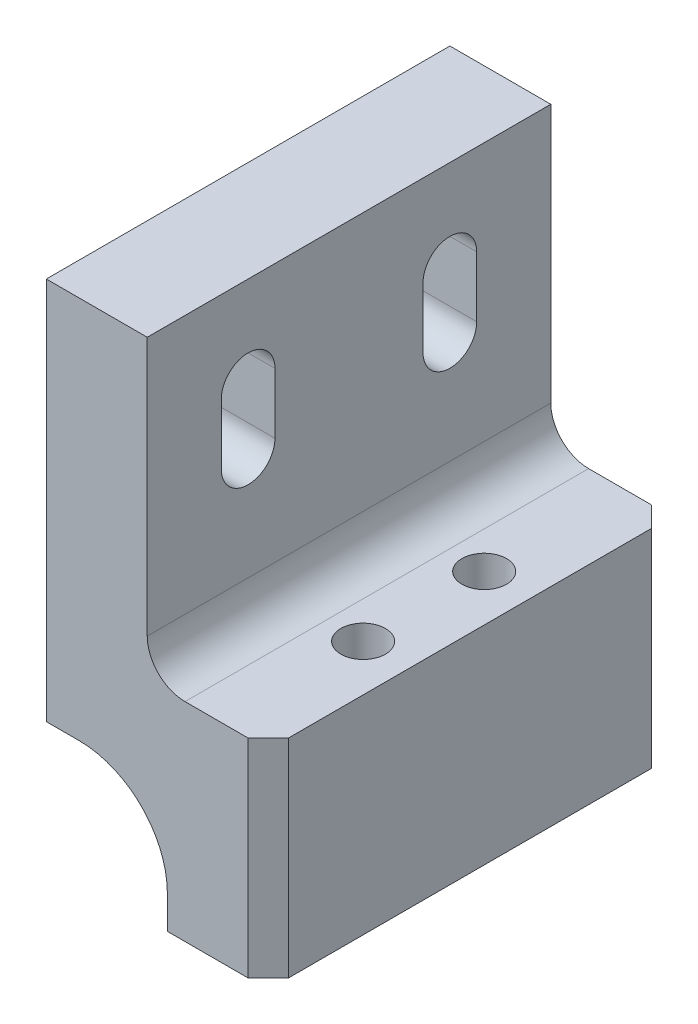
from build123d import *

# Parameters (mm, degrees)
SKETCH1_W              = 55.88
SKETCH1_H              = 63.5
EXTRUDE1_DEPTH         = 25.4
EXTRUDE1_DEPTH_BACK    = 25.4
EXTRUDE2_DEPTH         = 51.8
FILLET1_R              = 11.1125
F_10_CLEARANCE_HOLE1_D = 5.6134
LPATTERN1_COUNT        = 2
LPATTERN1_PITCH        = 15.24
SKETCH9_W              = 15.24
SKETCH9_H              = 37.338
EXTRUDE3_DEPTH         = 51.8
FILLET2_R              = 4.7625
EXTRUDE5_DEPTH         = 13.7
LPATTERN2_COUNT        = 2
LPATTERN2_PITCH        = 25.4
CHAMFER1_SIZE          = 2.54


with BuildPart() as part:
    # Sketch1 → Extrude1 (new body, two sides)
    with BuildSketch(Plane.XY) as extrude1_sk:
        Rectangle(SKETCH1_W, SKETCH1_H)
    extrude(amount=EXTRUDE1_DEPTH)
    extrude(extrude1_sk.sketch, amount=-EXTRUDE1_DEPTH_BACK)

    # Sketch2 → Extrude2 (cut, through all)
    with BuildSketch(Plane.XY.offset(25.4)):
        Polygon((-27.94, -31.75), (15.24, -31.75), (15.24, -16.51), (0, -16.51), (0, 31.75), (-27.94, 31.75), align=None)
    extrude(amount=-EXTRUDE2_DEPTH, mode=Mode.SUBTRACT)

    # Fillet1
    fillet1_edges = [part.edges().sort_by_distance(p)[0] for p in [
        (15.24, -16.51, 0),
    ]]
    fillet(fillet1_edges, radius=FILLET1_R)

    # 10 Clearance Hole1 (through all)
    with Locations(Plane(origin=(0, 31.75, 0), x_dir=(-1, 0, 0), z_dir=(0, 1, 0))):
        with Locations((-22.098, -7.62)):
            f_10_clearance_hole1 = Hole(F_10_CLEARANCE_HOLE1_D / 2)

    # LPattern1: 10 Clearance Hole1 ×2
    with Locations(*[(0, 0, i * LPATTERN1_PITCH) for i in range(1, LPATTERN1_COUNT)]):
        add(f_10_clearance_hole1, mode=Mode.SUBTRACT)

    # Sketch9 → Extrude3 (cut, through all)
    with BuildSketch(Plane.XY.offset(25.4)):
        with Locations((20.32, 13.081)):
            Rectangle(SKETCH9_W, SKETCH9_H)
    extrude(amount=-EXTRUDE3_DEPTH, mode=Mode.SUBTRACT)

    # Fillet2
    fillet2_edges = [part.edges().sort_by_distance(p)[0] for p in [
        (12.7, -5.588, 0),
    ]]
    fillet(fillet2_edges, radius=FILLET2_R)

    # Sketch11 → Extrude5 (cut, through all)
    with BuildSketch(Plane(origin=(12.7, 0, 0), x_dir=(0, 0, -1), z_dir=(1, 0, 0))):
        with BuildLine():
            Line((-9.3218, 20.32), (-9.3218, 12.7))
            ThreePointArc((-9.3218, 12.7), (-12.7, 9.3218), (-16.0782, 12.7))
            Line((-16.0782, 12.7), (-16.0782, 20.32))
            ThreePointArc((-16.0782, 20.32), (-12.7, 23.6982), (-9.3218, 20.32))
        make_face()
    extrude5 = extrude(amount=-EXTRUDE5_DEPTH, mode=Mode.SUBTRACT)

    # LPattern2: Extrude5 ×2
    with Locations(*[(0, 0, -i * LPATTERN2_PITCH) for i in range(1, LPATTERN2_COUNT)]):
        add(extrude5, mode=Mode.SUBTRACT)

    # Chamfer1
    chamfer1_edges = [part.edges().sort_by_distance(p)[0] for p in [
        (27.94, -18.669, -25.4),
        (27.94, -18.669, 25.4),
    ]]
    chamfer(chamfer1_edges, length=CHAMFER1_SIZE)


solid = part.part
